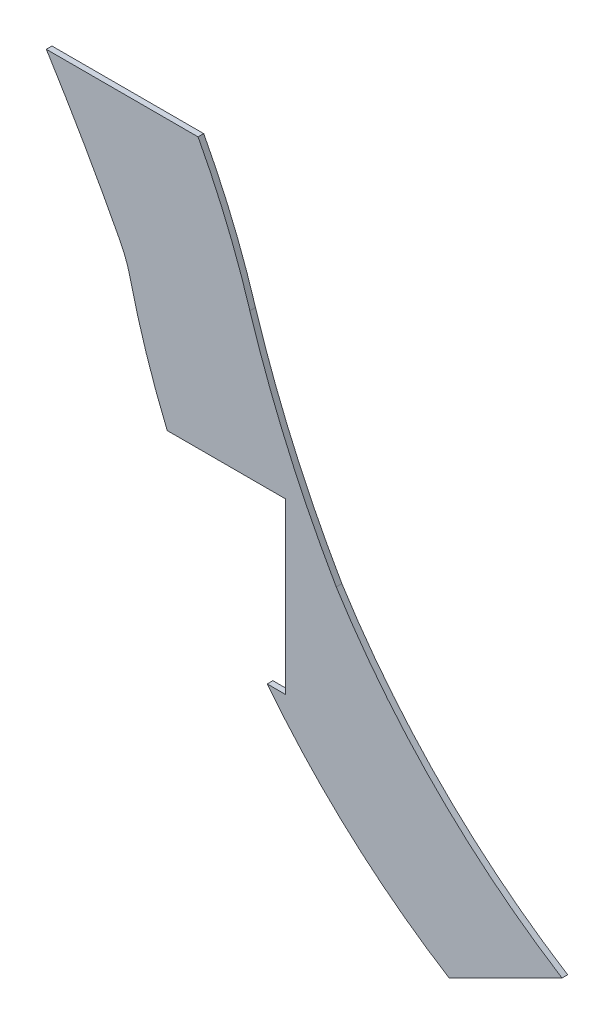
from build123d import *

# Parameters (mm, degrees)
SALIENTE_EXTRUIR1_DEPTH = 0.1


with BuildPart() as part:
    # Model → Saliente-Extruir1 (new body)
    with BuildSketch(Plane.XY):
        with BuildLine():
            Line((34.649371272, 11.960982991), (32.649371272, 10.960982991))
            ThreePointArc((32.649371272, 10.960982991), (30.912697203, 12.270631548), (29.428783982, 13.860982991))
            Line((29.428783982, 13.860982991), (29.750628728, 13.860982991))
            Line((29.750628728, 13.860982991), (29.750628728, 16.860982991))
            Line((29.750628728, 16.860982991), (27.658106466, 16.860982991))
            ThreePointArc((27.658106466, 16.860982991), (27.286967067, 17.858065763), (26.999339741, 18.882365051))
            ThreePointArc((26.999339741, 18.882365051), (26.927371, 19.119642667), (26.826595189, 19.346191565))
            ThreePointArc((26.826595189, 19.346191565), (26.1936862, 20.505212953), (25.516639133, 21.639017009))
            Line((25.516639133, 21.639017009), (28.203922027, 21.639017009))
            ThreePointArc((28.203922027, 21.639017009), (28.714965722, 20.556705993), (29.121100427, 19.430820834))
            ThreePointArc((29.121100427, 19.430820834), (29.792213257, 17.653647808), (30.650628728, 15.958991716))
            ThreePointArc((30.650628728, 15.958991716), (32.427042415, 13.736988846), (34.649371272, 11.960982991))
        make_face()
    extrude(amount=SALIENTE_EXTRUIR1_DEPTH)


solid = part.part
